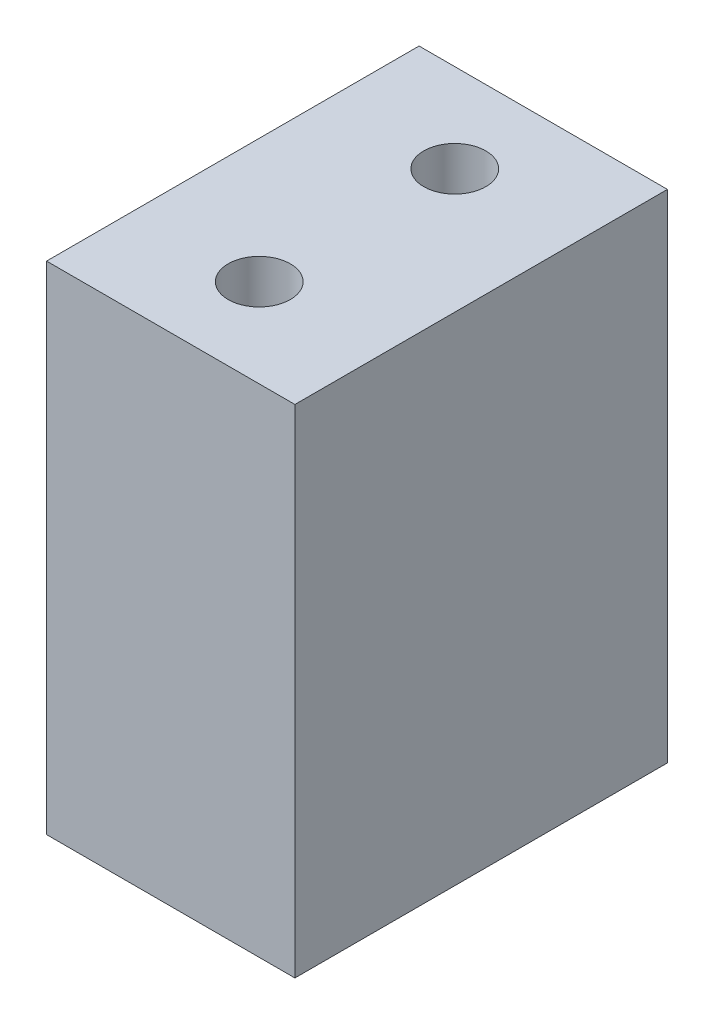
from build123d import *

# Parameters (mm, degrees)
SKETCH1_W           = 25.4
SKETCH1_H           = 38.1
SKETCH1_R           = 3.175
BOSS_EXTRUDE1_DEPTH = 50.8


with BuildPart() as part:
    # Sketch1 → Boss-Extrude1 (new body)
    with BuildSketch(Plane(origin=(0, 0, 0), x_dir=(1, 0, 0), z_dir=(0, 1, 0))):
        Rectangle(SKETCH1_W, SKETCH1_H)
        with Locations((0, 9.999999939)):
            Circle(SKETCH1_R, mode=Mode.SUBTRACT)
        with Locations((0, -9.999999939)):
            Circle(SKETCH1_R, mode=Mode.SUBTRACT)
    extrude(amount=BOSS_EXTRUDE1_DEPTH)


solid = part.part
